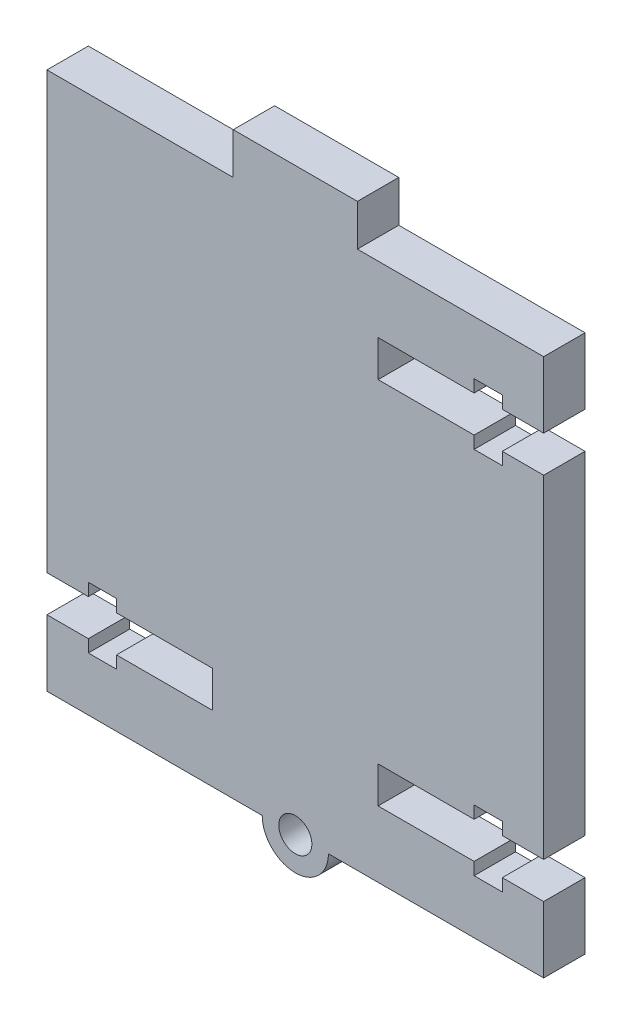
from build123d import *

# Parameters (mm, degrees)
BOSS_EXTRUDE1_DEPTH = 5
CUT_EXTRUDE1_DEPTH  = 5
SKETCH5_R           = 4
SKETCH5_R_2         = 2
BOSS_EXTRUDE2_DEPTH = 5
SKETCH6_R           = 2
CUT_EXTRUDE2_DEPTH  = 5


with BuildPart() as part:
    # Sketch1 → Boss-Extrude1 (new body)
    with BuildSketch(Plane.XY):
        Polygon((7.5, 32.5), (7.5, 37.5), (-7.5, 37.5), (-7.5, 32.5), (-30, 32.5), (-30, -32.5), (30, -32.5), (30, 32.5), align=None)
    extrude(amount=BOSS_EXTRUDE1_DEPTH)

    # Sketch3 → Cut-Extrude1 (cut)
    with BuildSketch(Plane.XY.offset(5)):
        Polygon((30, 24.5), (25, 24.5), (25, 26), (21.6, 26), (21.6, 24.5), (10, 24.5), (10, 20.1), (21.6, 20.1), (21.6, 18.6), (25, 18.6), (25, 20.1), (30, 20.1), align=None)
        Polygon((30, -24.5), (30, -20.1), (25, -20.1), (25, -18.6), (21.6, -18.6), (21.6, -20.1), (10, -20.1), (10, -24.5), (21.6, -24.5), (21.6, -26), (25, -26), (25, -24.5), align=None)
        Polygon((-30, -24.5), (-25, -24.5), (-25, -26), (-21.6, -26), (-21.6, -24.5), (-10, -24.5), (-10, -20.1), (-21.6, -20.1), (-21.6, -18.6), (-25, -18.6), (-25, -20.1), (-30, -20.1), align=None)
    extrude(amount=-CUT_EXTRUDE1_DEPTH, mode=Mode.SUBTRACT)

    # Sketch5 → Boss-Extrude2 (add)
    with BuildSketch(Plane.XY.offset(5)):
        with Locations((0, -32.5)):
            Circle(SKETCH5_R)
        with Locations((0, -32.5)):
            Circle(SKETCH5_R_2, mode=Mode.SUBTRACT)
    extrude(amount=-BOSS_EXTRUDE2_DEPTH)

    # Sketch6 → Cut-Extrude2 (cut)
    with BuildSketch(Plane.XY.offset(5)):
        with Locations((0, -32.5)):
            Circle(SKETCH6_R)
    extrude(amount=-CUT_EXTRUDE2_DEPTH, mode=Mode.SUBTRACT)


solid = part.part
